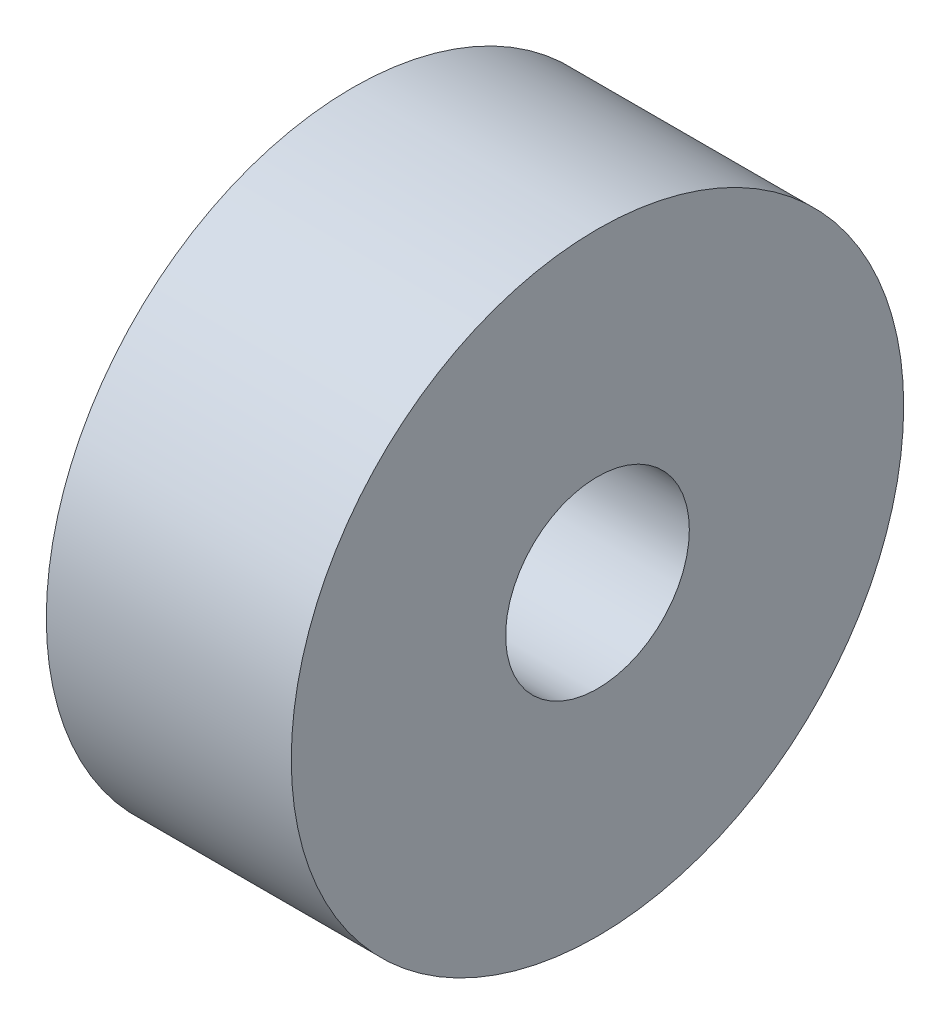
from build123d import *

# Parameters (mm, degrees)
ESQUISSE2_W             = 4
ESQUISSE2_H             = 5
ESQUISSE3_R             = 1.5
ENL_V_MAT_EXTRU_4_DEPTH = 5


with BuildPart() as part:
    # Esquisse2 → Révolution2 (revolve)
    with BuildSketch(Plane.XY):
        with Locations((2, 2.5)):
            Rectangle(ESQUISSE2_W, ESQUISSE2_H)
    revolve(axis=Axis((-2.508115562, 0, 0), (1, 0, 0)))

    # Esquisse3 → Enlèv. mat.-Extru.4 (cut, through all)
    with BuildSketch(Plane(origin=(0, 0, 0), x_dir=(0, 0, -1), z_dir=(1, 0, 0))):
        Circle(ESQUISSE3_R)
    extrude(amount=ENL_V_MAT_EXTRU_4_DEPTH, mode=Mode.SUBTRACT)


solid = part.part
